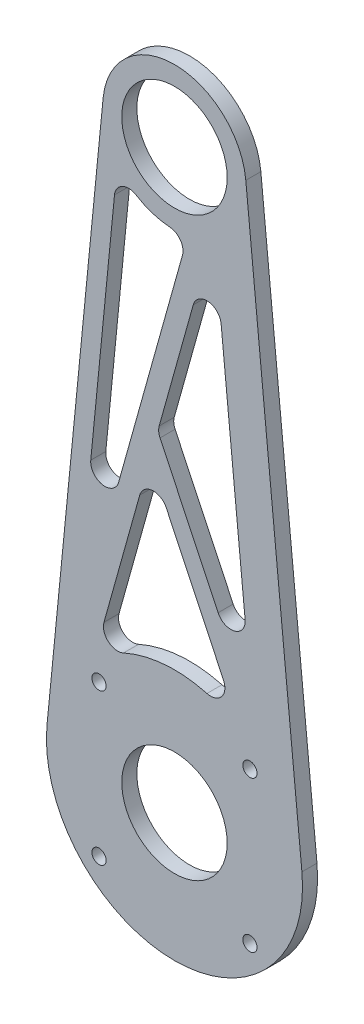
from build123d import *

# Parameters (mm, degrees)
SKETCH1_R           = 27
SKETCH1_R_2         = 11.1125
SKETCH1_R_3         = 1.5
SKETCH1_R_4         = 15.1125
BOSS_EXTRUDE1_DEPTH = 3.175
CUT_EXTRUDE1_DEPTH  = 3.175
FILLET1_R           = 3


with BuildPart() as part:
    # Sketch1 → Boss-Extrude1 (new body)
    with BuildSketch(Plane.XY):
        Circle(SKETCH1_R)
        Circle(SKETCH1_R_2, mode=Mode.SUBTRACT)
        with Locations((15.909902577, 15.909902577)):
            Circle(SKETCH1_R_3, mode=Mode.SUBTRACT)
        with Locations((15.909902577, -15.909902577)):
            Circle(SKETCH1_R_3, mode=Mode.SUBTRACT)
        with Locations((-15.909902577, -15.909902577)):
            Circle(SKETCH1_R_3, mode=Mode.SUBTRACT)
        with Locations((-15.909902577, 15.909902577)):
            Circle(SKETCH1_R_3, mode=Mode.SUBTRACT)
        with BuildLine():
            ThreePointArc((15.1125, 121.52122), (-0.740058556, 106.426851196), (-15.040018721, 122.999561344))
            Line((-15.040018721, 122.999561344), (-26.87050491, 2.64120538))
            ThreePointArc((-26.87050491, 2.64120538), (0, 27), (26.87050491, 2.64120538))
            Line((26.87050491, 2.64120538), (15.040018721, 122.999561344))
            ThreePointArc((15.040018721, 122.999561344), (15.094368804, 122.261278556), (15.1125, 121.52122))
        make_face()
        with Locations((0, 121.52122)):
            Circle(SKETCH1_R_4)
        with Locations((0, 121.52122)):
            Circle(SKETCH1_R_2, mode=Mode.SUBTRACT)
    extrude(amount=BOSS_EXTRUDE1_DEPTH)

    # Sketch2 → Cut-Extrude1 (cut)
    with BuildSketch(Plane(origin=(0, 0, 0), x_dir=(-1, 0, 0), z_dir=(0, 0, -1))):
        with BuildLine():
            Line((21.005906623, 21.414723514), (-2.816362401, 106.673467339))
            ThreePointArc((-2.816362401, 106.673467339), (5.441374418, 107.422315763), (12.061107277, 112.415323695))
            Line((12.061107277, 112.415323695), (21.005906623, 21.414723514))
        make_face()
        Polygon((2.538490153, 65.851704894), (3.524956455, 67.930383746), (-8.266368844, 110.130964305), (-16.578304393, 25.568852363), align=None)
        with BuildLine():
            Line((16.957069467, 19.857503654), (5.165744168, 62.058084212))
            Line((5.165744168, 62.058084212), (-13.749853367, 22.199193423))
            ThreePointArc((-13.749853367, 22.199193423), (1.98555698, 26.036901116), (16.957069467, 19.857503654))
        make_face()
    extrude(amount=-CUT_EXTRUDE1_DEPTH, mode=Mode.SUBTRACT)

    # Fillet1
    fillet1_edges = [part.edges().sort_by_distance(p)[0] for p in [
        (2.816362401, 106.673467339, 1.5875),
        (-12.061107277, 112.415323695, 1.5875),
        (-21.005906623, 21.414723514, 1.5875),
        (8.266368844, 110.130964305, 1.5875),
        (-3.524956455, 67.930383746, 1.5875),
        (16.578304393, 25.568852363, 1.5875),
        (13.749853367, 22.199193423, 1.5875),
        (-5.165744168, 62.058084212, 1.5875),
        (-16.957069467, 19.857503654, 1.5875),
    ]]
    fillet(fillet1_edges, radius=FILLET1_R)


solid = part.part
